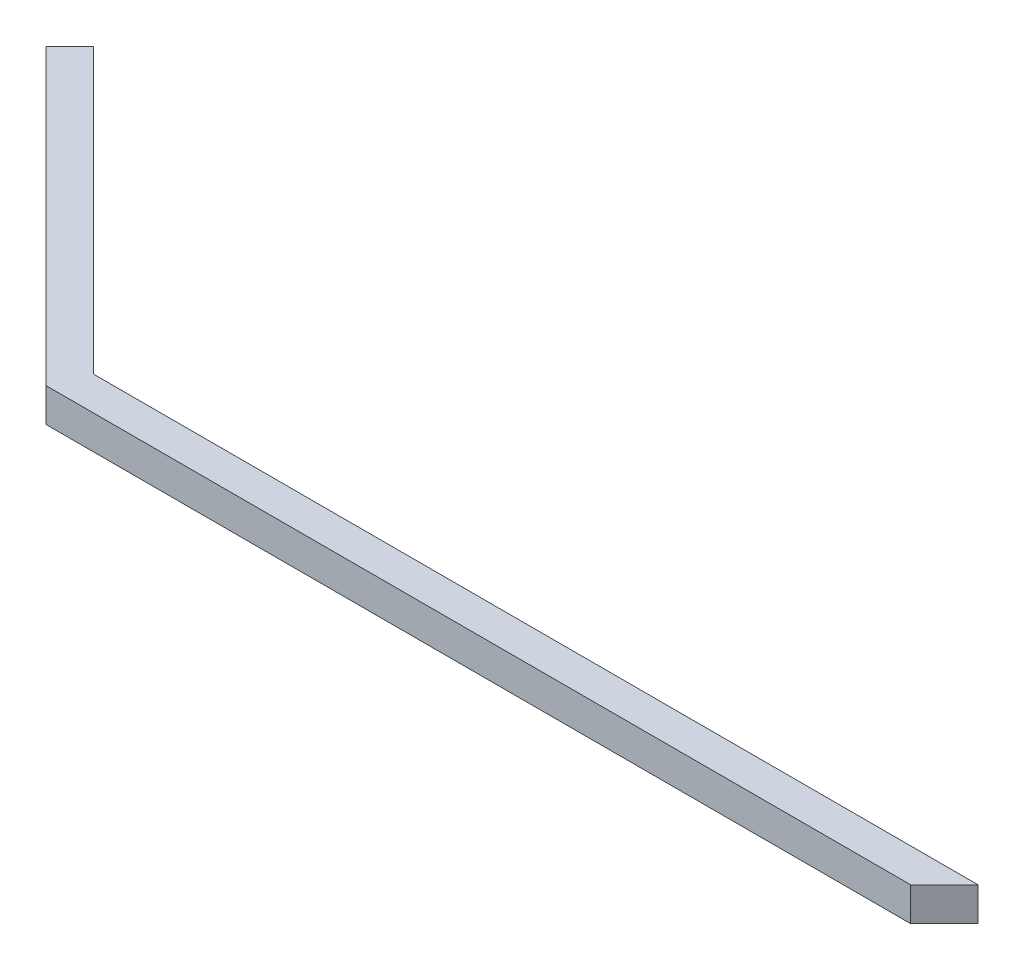
from build123d import *

# Parameters (mm, degrees)
BOSS_EXTRUDE1_DEPTH = 3


with BuildPart() as part:
    # Sketch1 → Boss-Extrude1 (new body)
    with BuildSketch(Plane(origin=(0, 0, 0), x_dir=(1, 0, 0), z_dir=(0, 1, 0))):
        Polygon((-125.738329701, 56.627665042), (-99.575378798, 30.464714138), (-22.575378798, 30.464714138), (-19.575378798, 33.464714138), (-22.575378798, 33.464714138), (-98.33273811, 33.464714138), (-123.617009358, 58.748985386), align=None)
    extrude(amount=BOSS_EXTRUDE1_DEPTH)


solid = part.part
